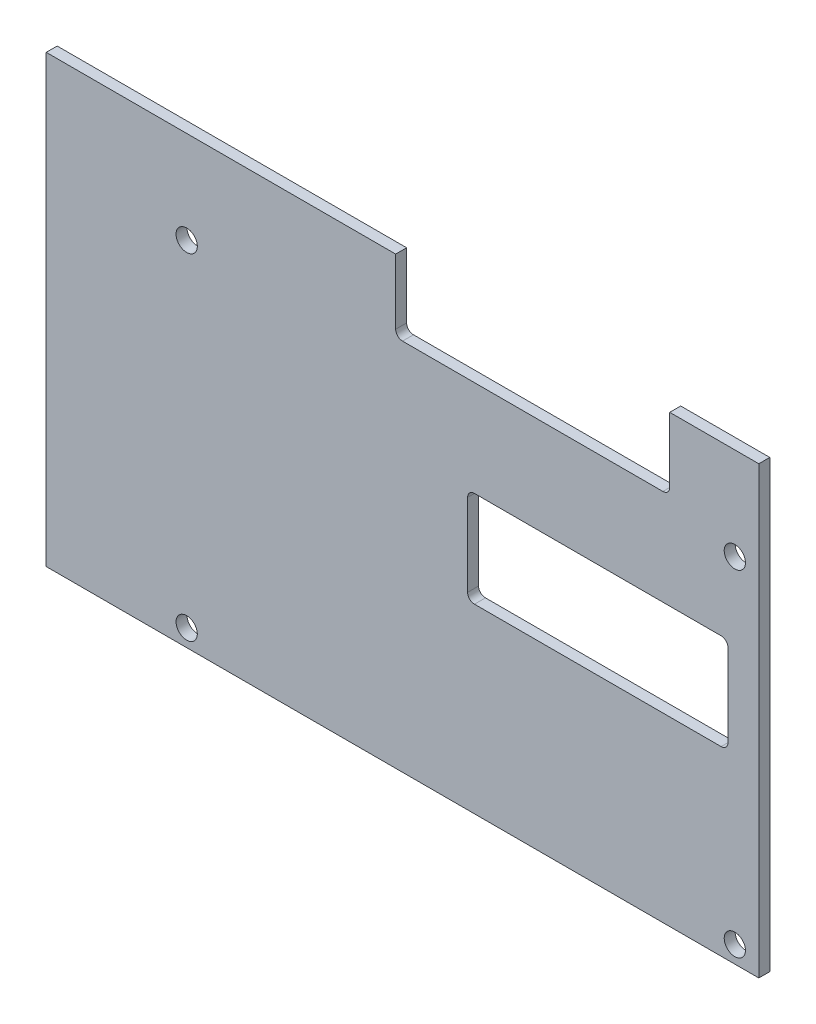
from build123d import *

# Parameters (mm, degrees)
SKETCH_1_R      = 1.55
EXTRUDE_1_DEPTH = 1.6


with BuildPart() as part:
    # Эскиз1 → Бобышка-Вытянуть1 (new body)
    with BuildSketch(Plane.XY):
        with BuildLine():
            Line((0, 65), (51, 65))
            Line((51, 65), (51, 55.5))
            ThreePointArc((51, 55.5), (51.292893219, 54.792893219), (52, 54.5))
            Line((52, 54.5), (90, 54.5))
            ThreePointArc((90, 54.5), (90.707106781, 54.792893219), (91, 55.5))
            Line((91, 55.5), (91, 65))
            Line((91, 65), (104, 65))
            Line((104, 65), (104, 0))
            Line((104, 0), (0, 0))
            Line((0, 0), (0, 65))
        make_face()
        with Locations((20.5, 51.5)):
            Circle(SKETCH_1_R, mode=Mode.SUBTRACT)
        with Locations((100.5, 51.5)):
            Circle(SKETCH_1_R, mode=Mode.SUBTRACT)
        with Locations((100.5, 2.5)):
            Circle(SKETCH_1_R, mode=Mode.SUBTRACT)
        with Locations((20.5, 2.5)):
            Circle(SKETCH_1_R, mode=Mode.SUBTRACT)
        with BuildLine():
            Line((62.5, 40.5), (98.5, 40.5))
            ThreePointArc((98.5, 40.5), (99.207106781, 40.207106781), (99.5, 39.5))
            Line((99.5, 39.5), (99.5, 27.5))
            ThreePointArc((99.5, 27.5), (99.207106781, 26.792893219), (98.5, 26.5))
            Line((98.5, 26.5), (62.5, 26.5))
            ThreePointArc((62.5, 26.5), (61.792893219, 26.792893219), (61.5, 27.5))
            Line((61.5, 27.5), (61.5, 39.5))
            ThreePointArc((61.5, 39.5), (61.792893219, 40.207106781), (62.5, 40.5))
        make_face(mode=Mode.SUBTRACT)
    extrude(amount=EXTRUDE_1_DEPTH)


solid = part.part
